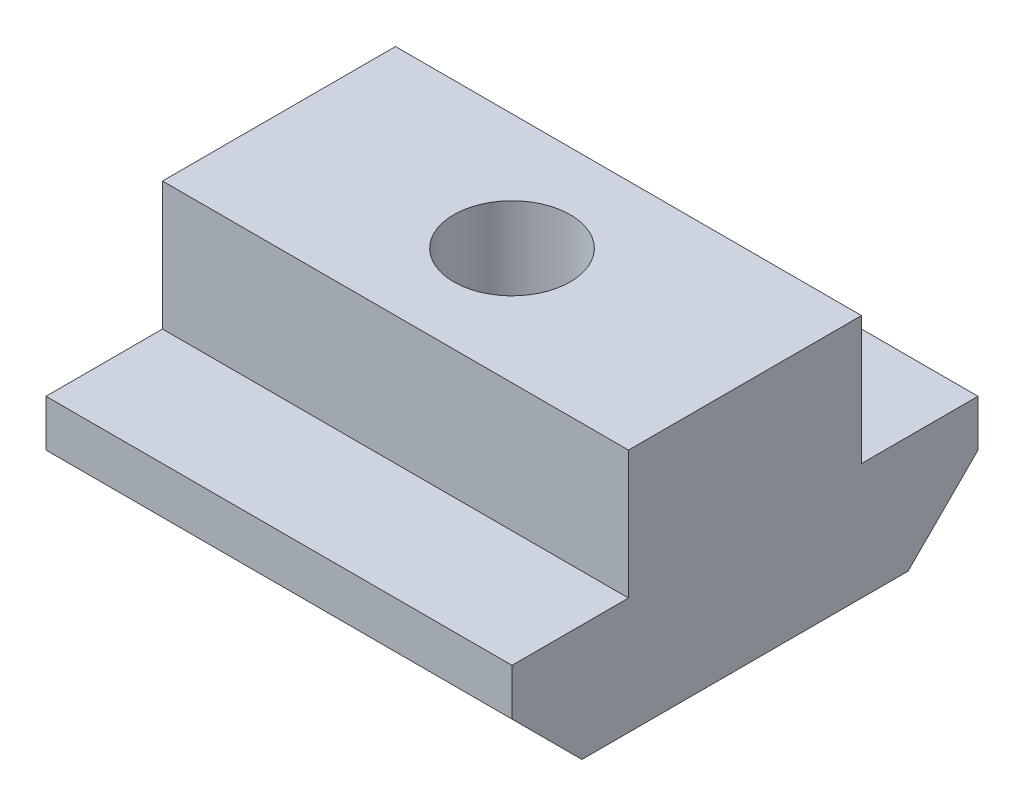
from build123d import *

# Parameters (mm, degrees)
EXTRUDE_1_DEPTH     = 20
SKETCH_2_R          = 2.5
CUT_EXTRUDE_1_DEPTH = 11.5


with BuildPart() as part:
    # Эскиз1 → Бобышка-Вытянуть1 (new body)
    with BuildSketch(Plane(origin=(0, 0, 0), x_dir=(0, 0, -1), z_dir=(1, 0, 0))):
        Polygon((-7, -5.25), (7, -5.25), (10, -2.25), (10, -0.25), (5, -0.25), (5, 5.25), (-5, 5.25), (-5, -0.25), (-10, -0.25), (-10, -2.25), align=None)
    extrude(amount=EXTRUDE_1_DEPTH)

    # Эскиз2 → Вырез-Вытянуть1 (cut, through all)
    with BuildSketch(Plane(origin=(0, 5.25, 0), x_dir=(1, 0, 0), z_dir=(0, 1, 0))):
        with Locations((10, 0)):
            Circle(SKETCH_2_R)
    extrude(amount=-CUT_EXTRUDE_1_DEPTH, mode=Mode.SUBTRACT)


solid = part.part
